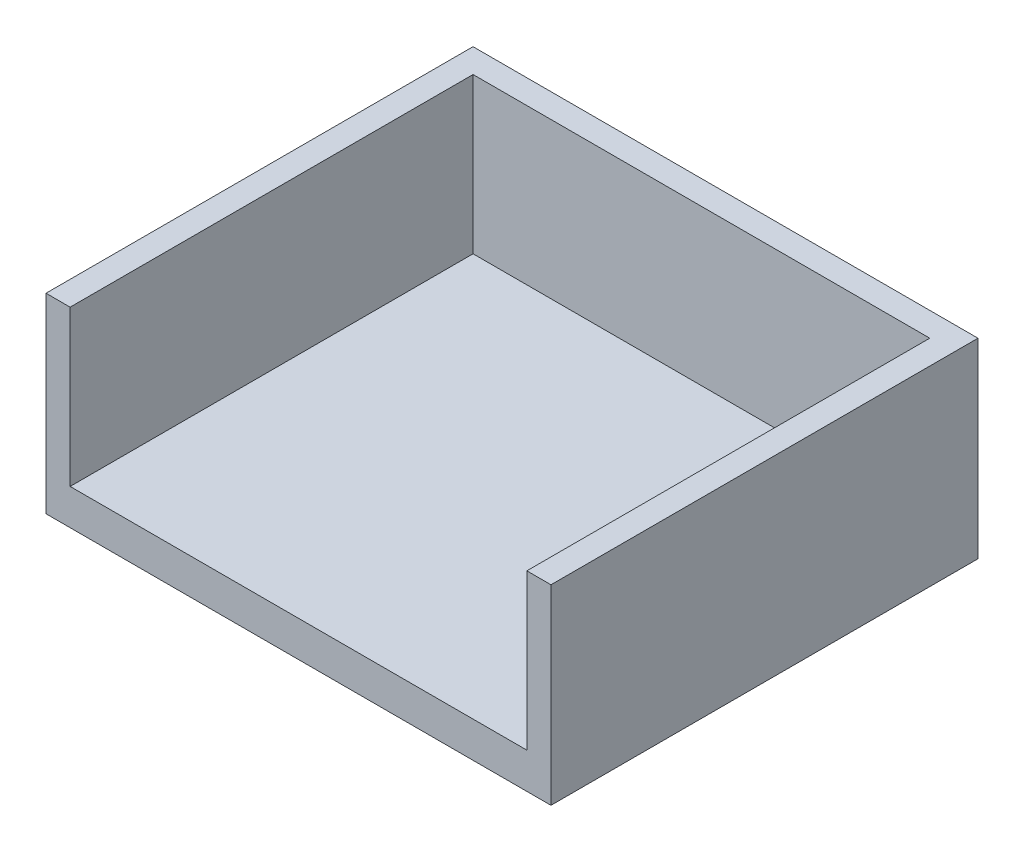
from build123d import *

# Parameters (mm, degrees)
SKETCH1_W           = 113.01
SKETCH1_H           = 95.57
BOSS_EXTRUDE1_DEPTH = 42.75
SKETCH3_W           = 102.21
SKETCH3_H           = 90.17
CUT_EXTRUDE1_DEPTH  = 34.75
SKETCH6_W           = 102.21
SKETCH6_H           = 8.948308689
CUT_EXTRUDE2_DEPTH  = 34.75


with BuildPart() as part:
    # Sketch1 → Boss-Extrude1 (new body)
    with BuildSketch(Plane(origin=(0, 0, 0), x_dir=(1, 0, 0), z_dir=(0, 1, 0))):
        Rectangle(SKETCH1_W, SKETCH1_H)
    extrude(amount=BOSS_EXTRUDE1_DEPTH)

    # Sketch3 → Cut-Extrude1 (cut)
    with BuildSketch(Plane(origin=(0, 42.75, 0), x_dir=(1, 0, 0), z_dir=(0, 1, 0))):
        with Locations((0, -2.692303692)):
            Rectangle(SKETCH3_W, SKETCH3_H)
    extrude(amount=-CUT_EXTRUDE1_DEPTH, mode=Mode.SUBTRACT)

    # Sketch6 → Cut-Extrude2 (cut)
    with BuildSketch(Plane(origin=(0, 42.75, 0), x_dir=(1, 0, 0), z_dir=(0, 1, 0))):
        with Locations((0, -47.777303693)):
            Rectangle(SKETCH6_W, SKETCH6_H)
    extrude(amount=-CUT_EXTRUDE2_DEPTH, mode=Mode.SUBTRACT)


solid = part.part
